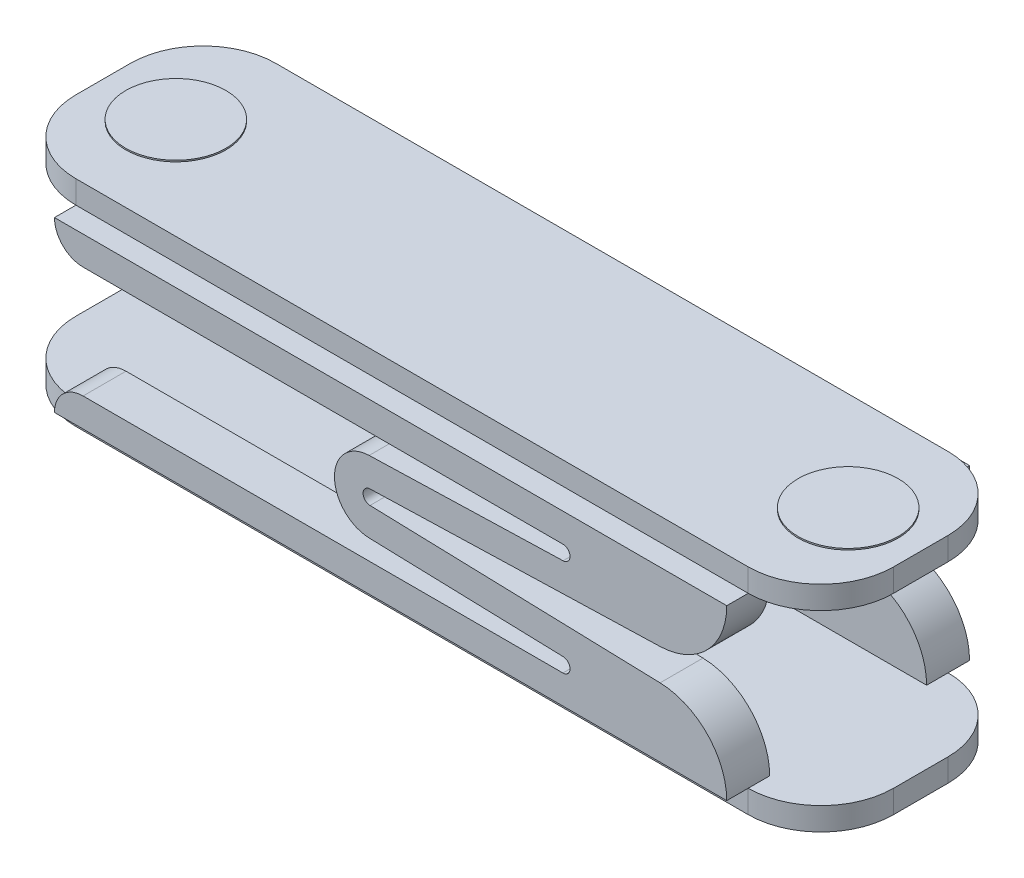
from build123d import *

# Parameters (mm, degrees)
SKETCH1_W             = 57.15
SKETCH1_H             = 1.6
BOSS_EXTRUDE1_DEPTH   = 13.97
BOSS_EXTRUDE1_2_DEPTH = 13.97
FILLET1_R             = 5.08
FILLET2_R             = 5.08
BOSS_EXTRUDE3_DEPTH   = 1.5
SKETCH3_R             = 3.5
BOSS_EXTRUDE4_DEPTH   = 0.1


with BuildPart() as part:
    # Sketch1 → Boss-Extrude1 (new body)
    with BuildSketch(Plane.XY):
        with Locations((-28.575, 0.8)):
            Rectangle(SKETCH1_W, SKETCH1_H)
    extrude(amount=BOSS_EXTRUDE1_DEPTH)

    # Fillet2
    fillet2_edges = [part.edges().sort_by_distance(p)[0] for p in [
        (-57.15, 0.8, 13.97),
        (0, 0.8, 13.97),
        (-57.15, 0.8, 0),
        (0, 0.8, 0),
    ]]
    fillet(fillet2_edges, radius=FILLET2_R)



with BuildPart() as body_2:
    # Sketch1 → Boss-Extrude1 2 (new body)
    with BuildSketch(Plane.XY):
        with Locations((-28.575, 14.2)):
            Rectangle(SKETCH1_W, SKETCH1_H)
    extrude(amount=BOSS_EXTRUDE1_2_DEPTH)

    # Fillet1
    fillet1_edges = [body_2.edges().sort_by_distance(p)[0] for p in [
        (-57.15, 14.2, 13.97),
        (0, 14.2, 13.97),
        (-57.15, 14.2, 0),
        (0, 14.2, 0),
    ]]
    fillet(fillet1_edges, radius=FILLET1_R)


with BuildPart() as part_1:
    add(part.part)

    add(body_2.part)  # Boss-Extrude3 merges body 2
    # Sketch2 → Boss-Extrude3 (add, symmetric)
    with BuildSketch(Plane.XY.offset(13.97)):
        with BuildLine():
            Line((-30.014795616, 7.999781042), (-9.740002775, 8.6))
            ThreePointArc((-9.740002775, 8.6), (-6.43662966, 10.055017718), (-5.08, 13.4))
            Line((-5.08, 13.4), (-52.07, 13.4))
            ThreePointArc((-52.07, 13.4), (-51.484213562, 11.985786438), (-50.07, 11.4))
            Line((-50.07, 11.4), (-16.532798801, 11.4))
            ThreePointArc((-16.532798801, 11.4), (-16.032853544, 10.907398618), (-16.518003185, 10.400218958))
            Line((-16.518003185, 10.400218958), (-30.073978082, 9.998905209))
            ThreePointArc((-30.073978082, 9.998905209), (-32.5, 7.5), (-30.073978082, 5.001094791))
            Line((-30.073978082, 5.001094791), (-16.518003185, 4.599781042))
            ThreePointArc((-16.518003185, 4.599781042), (-16.032853544, 4.092601382), (-16.532798801, 3.6))
            Line((-16.532798801, 3.6), (-50.07, 3.6))
            ThreePointArc((-50.07, 3.6), (-51.484213562, 3.014213562), (-52.07, 1.6))
            Line((-52.07, 1.6), (-5.08, 1.6))
            ThreePointArc((-5.08, 1.6), (-6.43662966, 4.944982282), (-9.740002775, 6.4))
            Line((-9.740002775, 6.4), (-30.014795616, 7.000218958))
            ThreePointArc((-30.014795616, 7.000218958), (-30.5, 7.5), (-30.014795616, 7.999781042))
        make_face()
    boss_extrude3 = extrude(amount=BOSS_EXTRUDE3_DEPTH, both=True)

    # Mirror2: Boss-Extrude3 across plane
    add(boss_extrude3.mirror(Plane(origin=(0, 0, 6.985), x_dir=(1, 0, 0), z_dir=(0, 0, -1))))

    # Sketch3 → Boss-Extrude4 (add)
    with BuildSketch(Plane(origin=(0, 15, 0), x_dir=(1, 0, 0), z_dir=(0, 1, 0))):
        with Locations((-5.08, -6.985)):
            Circle(SKETCH3_R)
        with Locations((-52.07, -6.985)):
            Circle(SKETCH3_R)
    boss_extrude4 = extrude(amount=BOSS_EXTRUDE4_DEPTH)

    # Mirror3: Boss-Extrude4 across plane
    add(boss_extrude4.mirror(Plane.ZX.offset(7.5)))


solid = part_1.part
